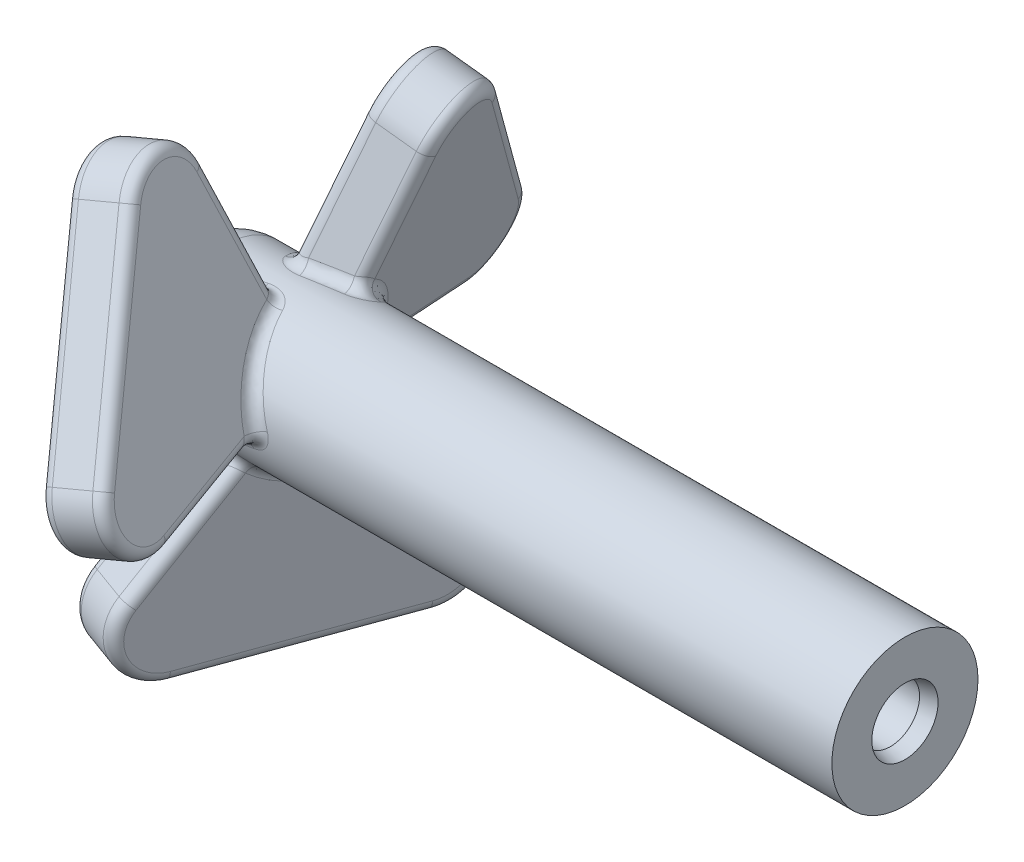
from build123d import *

# Parameters (mm, degrees)
SKETCH1_W           = 12.7
SKETCH1_H           = 1.27
BOSS_EXTRUDE1_DEPTH = 0.508
CIRPATTERN1_COUNT   = 3
FILLET1_R           = 0.889
FILLET3_R           = 0.1905
SKETCH8_R           = 0.508
CUT_EXTRUDE4_DEPTH  = 3.81
CHAMFER5_SIZE       = 0.254
CHAMFER5_SIZE2      = 0.068059095


with BuildPart() as part:
    # Sketch1 → Revolve1 (revolve)
    with BuildSketch(Plane.XY):
        with Locations((-6.35, 0.635)):
            Rectangle(SKETCH1_W, SKETCH1_H)
    revolve(axis=Axis((20.779409663, 0, 0), (-1, 0, 0)))

    # Sketch2 → Boss-Extrude1 (add, symmetric)
    with BuildSketch(Plane(origin=(-9.532224882, 0, -3.469446123), x_dir=(-0.34202014332566943, 0, 0.9396926207859081), z_dir=(-0.9396926207859081, 0, -0.34202014332566943))):
        with BuildLine():
            Line((3.692107447, 0), (6.076266543, -2.601853089))
            ThreePointArc((6.076266543, -2.601853089), (6.22263889, -3.488417324), (5.470107447, -3.979454425))
            Line((5.470107447, -3.979454425), (1.914107447, -3.979454425))
            ThreePointArc((1.914107447, -3.979454425), (1.161576004, -3.488417324), (1.307948352, -2.601853089))
            Line((1.307948352, -2.601853089), (3.692107447, 0))
        make_face()
    boss_extrude1 = extrude(amount=BOSS_EXTRUDE1_DEPTH, both=True)

    # CirPattern1: Boss-Extrude1 ×3 about axis
    cirpattern1_axis = Axis((0.635, 0, 0), (-1, 0, 0))
    for i in range(1, CIRPATTERN1_COUNT):
        add(boss_extrude1.rotate(cirpattern1_axis, i * 360 / CIRPATTERN1_COUNT))

    # Fillet1
    fillet1_edges = [part.edges().sort_by_distance(p)[0] for p in [
        (-12.7, -1.27, 0),
    ]]
    fillet(fillet1_edges, radius=FILLET1_R)

    # Fillet3
    fillet3_edges = [part.edges().sort_by_distance(p)[0] for p in [
        (-11.095094153, -0.962126911, 0.828982392),
        (-10.494905847, -0.962126911, -0.828982392),
        (-11.843536451, -1.822481881, 1.395537589),
        (-11.272363851, -3.979454425, -0.173746233),
        (-10.72811584, -1.736571642, -1.669055355),
        (-11.288878146, -1.263495241, -0.128373582),
        (-11.095094153, -0.236856356, -1.247717543),
        (-10.494905847, 1.198983267, -0.41873515),
        (-11.095094153, 1.198983267, 0.41873515),
        (-10.494905847, -0.236856356, 1.247717543),
        (-11.843536451, 2.119811944, 0.880546812),
        (-11.272363851, 1.839258561, 3.533181742),
        (-10.72811584, -0.577158517, 2.338442835),
        (-11.288878146, 0.520572837, 1.158405767),
        (-11.843536451, -0.297330063, -2.276084401),
        (-11.272363851, 2.140195864, -3.359435509),
        (-10.72811584, 2.313730159, -0.669387479),
        (-11.288878146, 0.742922404, -1.030032185),
        (-10.317636149, 1.839258561, -3.533181742),
        (-10.86188416, -0.577158517, -2.338442835),
        (-10.301121854, 0.520572837, -1.158405767),
        (-9.746463549, 2.119811944, -0.880546812),
        (-10.317636149, 2.140195864, 3.359435509),
        (-10.86188416, 2.313730159, 0.669387479),
        (-10.301121854, 0.742922404, 1.030032185),
        (-9.746463549, -0.297330063, 2.276084401),
        (-10.317636149, -3.979454425, 0.173746233),
        (-10.86188416, -1.736571642, 1.669055355),
        (-10.301121854, -1.263495241, 0.128373582),
        (-9.746463549, -1.822481881, -1.395537589),
        (-12.137856578, 3.653080632, 1.918970276),
        (-10.406871124, -0.46560061, 4.296892),
        (-12.137856578, -0.164663307, -4.123145767),
        (-10.406871124, 3.954017935, -1.745224043),
        (-9.452143422, 3.653080632, -1.918970276),
        (-11.183128876, -0.46560061, -4.296892),
        (-9.452143422, -0.164663307, 4.123145767),
        (-11.183128876, 3.954017935, 1.745224043),
        (-9.452143422, -3.488417324, -2.204175491),
        (-11.183128876, -3.488417324, 2.551667957),
        (-12.137856578, -3.488417324, 2.204175491),
        (-10.406871124, -3.488417324, -2.551667957),
    ]]
    fillet(fillet3_edges, radius=FILLET3_R)

    # Sketch8 → Cut-Extrude4 (cut)
    with BuildSketch(Plane(origin=(0, 0, 0), x_dir=(0, 0, -1), z_dir=(1, 0, 0))):
        Circle(SKETCH8_R)
    extrude(amount=-CUT_EXTRUDE4_DEPTH, mode=Mode.SUBTRACT)

    # Chamfer5
    chamfer5_edges = [part.edges().sort_by_distance(p)[0] for p in [
        (0, 0, 0.508),
    ]]
    chamfer5_side = [part.faces().sort_by_distance(p)[0] for p in [
        (-1.905, 0, 0.508),
    ]]
    chamfer(chamfer5_edges, length=CHAMFER5_SIZE, length2=CHAMFER5_SIZE2, reference=chamfer5_side[0])


solid = part.part
